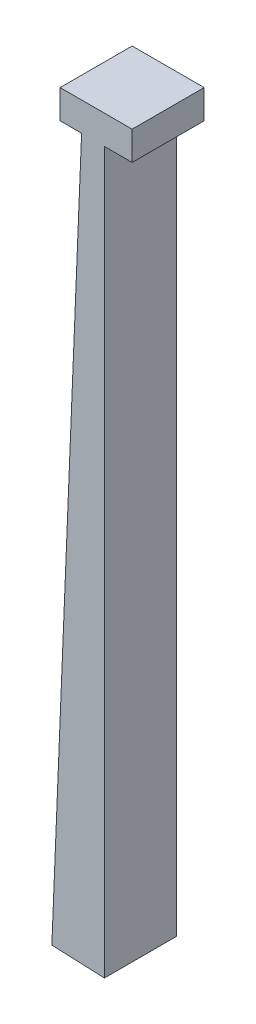
from build123d import *

# Parameters (mm, degrees)
BOSS_EXTRUDE1_DEPTH = 50


with BuildPart() as part:
    # Sketch1 → Boss-Extrude1 (new body)
    with BuildSketch(Plane.XY):
        Polygon((15.05518629, 93.72842378), (9.296047762, 93.72842378), (-0.786164341, 93.72842378), (-21.44867742, -404.758474142), (15.05518629, -406.27157622), align=None)
        Polygon((-0.786164341, 93.72842378), (9.296047762, 93.72842378), (15.05518629, 93.72842378), (34.296047762, 93.72842378), (34.296047762, 113.72842378), (-15.703952238, 113.72842378), (-15.703952238, 93.72842378), align=None)
    extrude(amount=BOSS_EXTRUDE1_DEPTH)


solid = part.part
